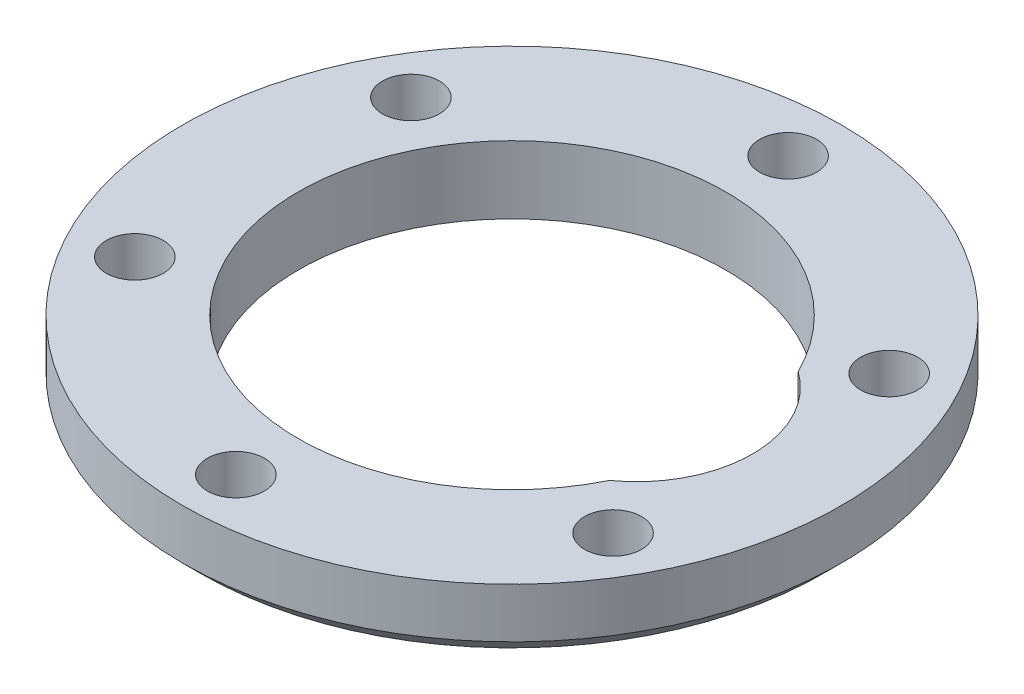
from build123d import *

# Parameters (mm, degrees)
SKETCH_1_R      = 18.5
SKETCH_1_R_2    = 1.6
EXTRUDE_1_DEPTH = 3.8
CHAMFER_1_SIZE  = 1


with BuildPart() as part:
    # Эскиз1 → Бобышка-Вытянуть1 (new body)
    with BuildSketch(Plane(origin=(0, 0, 0), x_dir=(1, 0, 0), z_dir=(0, 1, 0))):
        Circle(SKETCH_1_R)
        with Locations((-13.423393759, -7.75)):
            Circle(SKETCH_1_R_2, mode=Mode.SUBTRACT)
        with Locations((0, -15.5)):
            Circle(SKETCH_1_R_2, mode=Mode.SUBTRACT)
        with Locations((-13.423393759, 7.75)):
            Circle(SKETCH_1_R_2, mode=Mode.SUBTRACT)
        with Locations((0, 15.5)):
            Circle(SKETCH_1_R_2, mode=Mode.SUBTRACT)
        with Locations((13.423393759, 7.75)):
            Circle(SKETCH_1_R_2, mode=Mode.SUBTRACT)
        with Locations((13.423393759, -7.75)):
            Circle(SKETCH_1_R_2, mode=Mode.SUBTRACT)
        with BuildLine():
            ThreePointArc((10.767857143, -5.296532125), (13.5, 0), (10.767857143, 5.296532125))
            ThreePointArc((10.767857143, 5.296532125), (-12, 0), (10.767857143, -5.296532125))
        make_face(mode=Mode.SUBTRACT)
    extrude(amount=EXTRUDE_1_DEPTH)

    # Фаска1
    chamfer_1_edges = [part.edges().sort_by_distance(p)[0] for p in [
        (-18.5, 0, 0),
    ]]
    chamfer(chamfer_1_edges, length=CHAMFER_1_SIZE)


solid = part.part
